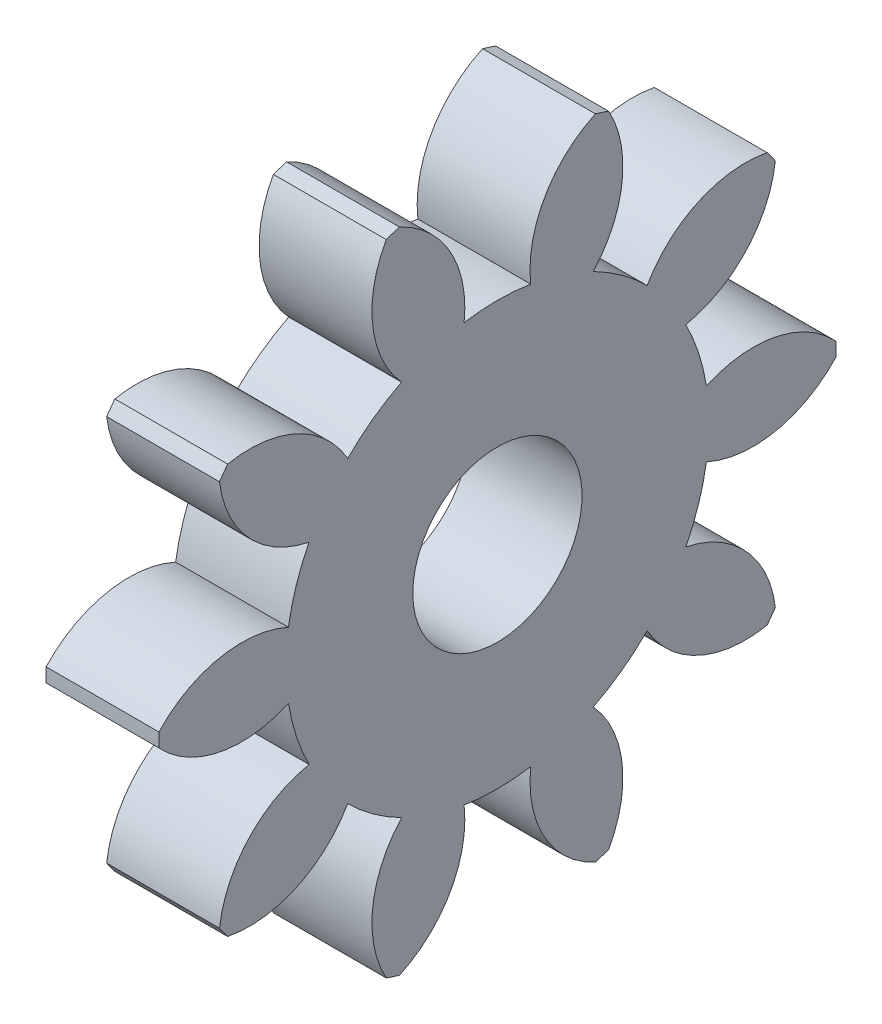
from build123d import *

# Parameters (mm, degrees)
BASPROSKE_W     = 3.175
BASPROSKE_H     = 9.525
TOOTHCUT_DEPTH  = 14.839504146
TEETHCUTS_COUNT = 10
TEETHCUTS_ANGLE = 324
BORSKE_R        = 2.38125
BORE_DEPTH      = 50.8000508


with BuildPart() as part:
    # BasProSke → Base-Revolve (revolve)
    with BuildSketch(Plane(origin=(0, 0, 0), x_dir=(1, 0, 0), z_dir=(0, 1, 0)), mode=Mode.PRIVATE) as base_revolve_sk:
        with Locations((1.5875, 4.7625)):
            Rectangle(BASPROSKE_W, BASPROSKE_H)
    revolve(base_revolve_sk.sketch.rotate(Axis((-10, 0, 0), (1, 0, 0)), 180), axis=Axis((-10, 0, 0), (1, 0, 0)))

    # TooCutSke → ToothCut (cut, through all)
    with BuildSketch(Plane(origin=(0, 0, 0), x_dir=(0, 0, -1), z_dir=(1, 0, 0))):
        with BuildLine():
            ThreePointArc((0.936848711, 5.877660456), (0, 5.951855), (-0.936848711, 5.877660456))
            ThreePointArc((-0.936848711, 5.877660456), (-1.332872851, 7.808253106), (-2.791788616, 9.133239101))
            ThreePointArc((-2.791788616, 9.133239101), (0, 9.5504), (2.791788616, 9.133239101))
            ThreePointArc((2.791788616, 9.133239101), (1.332872851, 7.808253106), (0.936848711, 5.877660456))
        make_face()
    toothcut = extrude(amount=TOOTHCUT_DEPTH, mode=Mode.SUBTRACT)

    # TeethCuts: ToothCut ×10 about axis
    teethcuts_axis = Axis((-10, 0, 0), (1, 0, 0))
    for i in range(1, TEETHCUTS_COUNT):
        add(toothcut.rotate(teethcuts_axis, i * TEETHCUTS_ANGLE / (TEETHCUTS_COUNT - 1)), mode=Mode.SUBTRACT)

    # BorSke → Bore (cut, symmetric)
    with BuildSketch(Plane(origin=(0, 0, 0), x_dir=(0, 0, -1), z_dir=(1, 0, 0))):
        with Locations(Location((0, 0, 0), (0, 0, 180))):
            Circle(BORSKE_R)
    extrude(amount=BORE_DEPTH, both=True, mode=Mode.SUBTRACT)


solid = part.part
